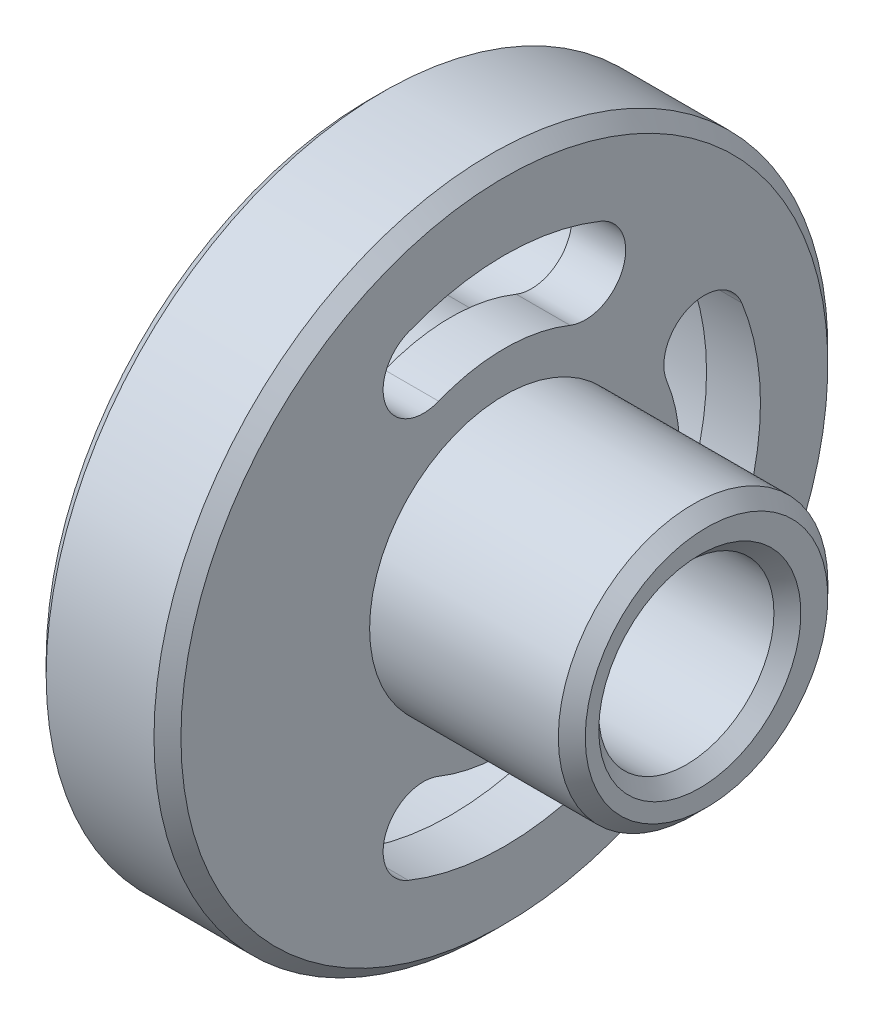
from build123d import *

# Parameters (mm, degrees)
CUT_EXTRUDE_2_DEPTH = 6
CUT_EXTRUDE_3_DEPTH = 26
SKETCH_3_R          = 6.5
CUT_EXTRUDE_4_DEPTH = 15
CHAMFER_1_SIZE      = 1


with BuildPart() as part:
    # Эскиз1 → Повернуть1 (revolve)
    with BuildSketch(Plane.XY):
        Polygon((0, 0), (0, 24), (1, 25), (9, 25), (10, 24), (10, 10), (24, 10), (25, 9), (25, 0), align=None)
    revolve(axis=Axis((0, 0, 0), (1, 0, 0)))

    # Эскиз4 → Вырез-Вытянуть2 (cut)
    with BuildSketch(Plane.ZY):
        with BuildLine():
            ThreePointArc((7.875, 19.467521029), (0, 21), (-7.875, 19.467521029))
            ThreePointArc((-7.875, 19.467521029), (-10.635124054, 12.957396974), (-4.125, 10.19727292))
            ThreePointArc((-4.125, 10.19727292), (0, 11), (4.125, 10.19727292))
            ThreePointArc((4.125, 10.19727292), (10.635124054, 12.957396974), (7.875, 19.467521029))
        make_face()
        with BuildLine():
            ThreePointArc((-10.19727292, 4.125), (-11, 0), (-10.19727292, -4.125))
            ThreePointArc((-10.19727292, -4.125), (-12.957396974, -10.635124054), (-19.467521029, -7.875))
            ThreePointArc((-19.467521029, -7.875), (-21, 0), (-19.467521029, 7.875))
            ThreePointArc((-19.467521029, 7.875), (-12.957396974, 10.635124054), (-10.19727292, 4.125))
        make_face()
        with BuildLine():
            ThreePointArc((-4.125, -10.19727292), (0, -11), (4.125, -10.19727292))
            ThreePointArc((4.125, -10.19727292), (10.635124054, -12.957396974), (7.875, -19.467521029))
            ThreePointArc((7.875, -19.467521029), (0, -21), (-7.875, -19.467521029))
            ThreePointArc((-7.875, -19.467521029), (-10.635124054, -12.957396974), (-4.125, -10.19727292))
        make_face()
    extrude(amount=-CUT_EXTRUDE_2_DEPTH, mode=Mode.SUBTRACT)

    # Эскиз5 → Вырез-Вытянуть3 (cut, through all)
    with BuildSketch(Plane.ZY):
        with BuildLine():
            ThreePointArc((7.125, 17.613471407), (0, 19), (-7.125, 17.613471407))
            ThreePointArc((-7.125, 17.613471407), (-8.781074433, 13.707396974), (-4.875, 12.051322542))
            ThreePointArc((-4.875, 12.051322542), (0, 13), (4.875, 12.051322542))
            ThreePointArc((4.875, 12.051322542), (8.781074433, 13.707396974), (7.125, 17.613471407))
        make_face()
        with BuildLine():
            ThreePointArc((-12.051322542, 4.875), (-13, 0), (-12.051322542, -4.875))
            ThreePointArc((-12.051322542, -4.875), (-13.707396974, -8.781074433), (-17.613471407, -7.125))
            ThreePointArc((-17.613471407, -7.125), (-19, 0), (-17.613471407, 7.125))
            ThreePointArc((-17.613471407, 7.125), (-13.707396974, 8.781074433), (-12.051322542, 4.875))
        make_face()
        with BuildLine():
            ThreePointArc((-4.875, -12.051322542), (0, -13), (4.875, -12.051322542))
            ThreePointArc((4.875, -12.051322542), (8.781074433, -13.707396974), (7.125, -17.613471407))
            ThreePointArc((7.125, -17.613471407), (0, -19), (-7.125, -17.613471407))
            ThreePointArc((-7.125, -17.613471407), (-8.781074433, -13.707396974), (-4.875, -12.051322542))
        make_face()
    extrude(amount=-CUT_EXTRUDE_3_DEPTH, mode=Mode.SUBTRACT)

    # Эскиз3 → Вырез-Вытянуть4 (cut)
    with BuildSketch(Plane(origin=(25, 0, 0), x_dir=(0, 0, -1), z_dir=(1, 0, 0))):
        with Locations((-0.5, 0)):
            Circle(SKETCH_3_R)
    extrude(amount=-CUT_EXTRUDE_4_DEPTH, mode=Mode.SUBTRACT)

    # Фаска1
    chamfer_1_edges = [part.edges().sort_by_distance(p)[0] for p in [
        (25, 0, 7),
    ]]
    chamfer(chamfer_1_edges, length=CHAMFER_1_SIZE)


solid = part.part
